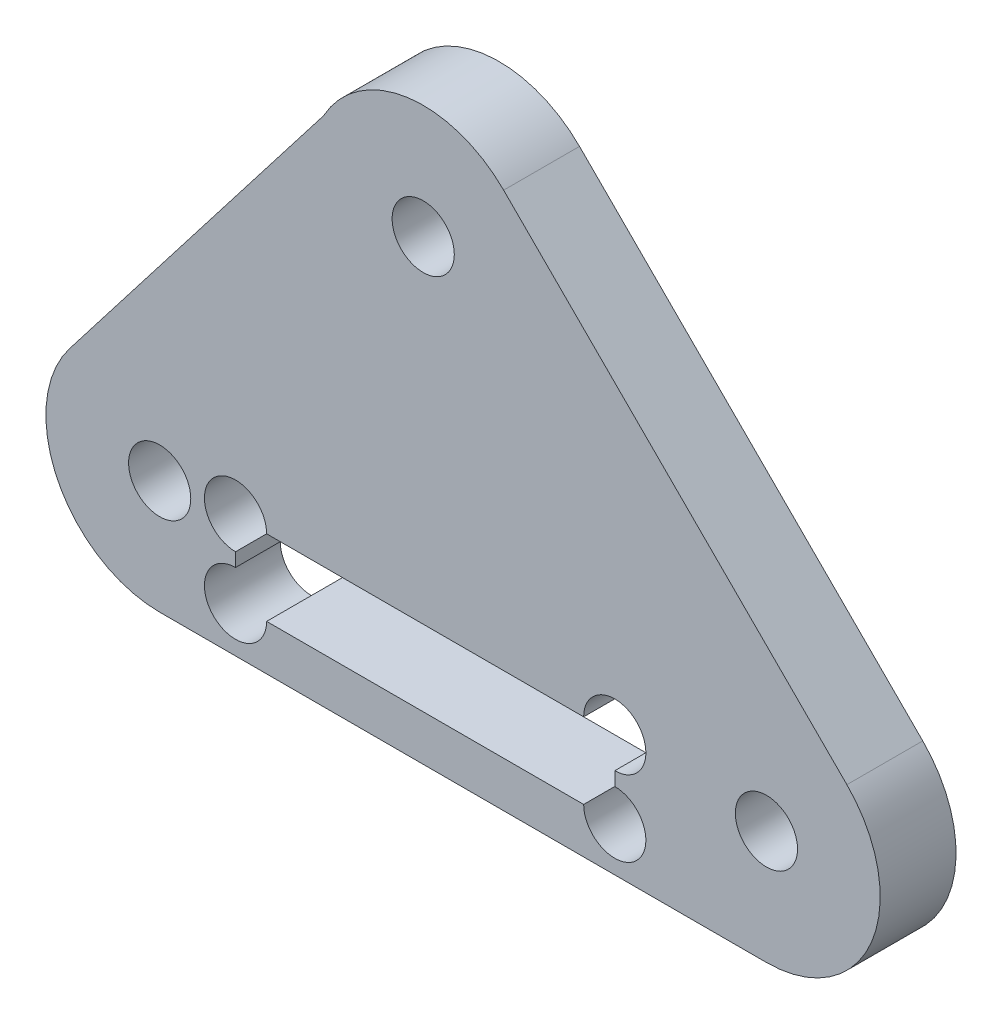
from build123d import *

# Parameters (mm, degrees)
SCHIZZO1_R                   = 2.05
SCHIZZO1_W                   = 25
SCHIZZO1_H                   = 5
ESTRUSIONE_ESTRUSIONE2_DEPTH = 5
CUT_EXTRUDE1_REACH           = 7
SKETCH1_R                    = 2.05


with BuildPart() as part:
    # Schizzo1 → Estrusione-Estrusione2 (new body)
    with BuildSketch(Plane.XY):
        with BuildLine():
            Line((-22.627416998, -7.5), (0, -7.5))
            ThreePointArc((0, -7.5), (6.929096494, -2.870125743), (5.303300859, 5.303300859))
            Line((5.303300859, 5.303300859), (-17.324116139, 27.930717857))
            ThreePointArc((-17.324116139, 27.930717857), (-23.686333927, 30.052287026), (-29.20181593, 26.236749163))
            Line((-29.20181593, 26.236749163), (-45.934294533, 4.586300077))
            ThreePointArc((-45.934294533, 4.586300077), (-46.732282324, -3.305506726), (-40, -7.5))
            Line((-40, -7.5), (-22.627416998, -7.5))
        make_face()
        Circle(SCHIZZO1_R, mode=Mode.SUBTRACT)
        with Locations((-22.627416998, 22.627416998)):
            Circle(SCHIZZO1_R, mode=Mode.SUBTRACT)
        with Locations((-40, 0)):
            Circle(SCHIZZO1_R, mode=Mode.SUBTRACT)
        with Locations((-22.5, -2)):
            Rectangle(SCHIZZO1_W, SCHIZZO1_H, mode=Mode.SUBTRACT)
    extrude(amount=ESTRUSIONE_ESTRUSIONE2_DEPTH)

    # Sketch1 → Cut-Extrude1 (cut, up to next)
    with BuildSketch(Plane.XY.offset(5), mode=Mode.PRIVATE) as cut_extrude1_sk1:
        with Locations((-35, 0.5)):
            Circle(SKETCH1_R)
    cut_extrude1_tool1 = extrude(cut_extrude1_sk1.sketch, amount=-CUT_EXTRUDE1_REACH, mode=Mode.PRIVATE) & part.part
    add(cut_extrude1_tool1.solids().sort_by_distance((-35, 0.5, 5))[0], mode=Mode.SUBTRACT)
    # Sketch1 → Cut-Extrude1 (cut, up to next)
    with BuildSketch(Plane.XY.offset(5), mode=Mode.PRIVATE) as cut_extrude1_sk2:
        with Locations((-35, -4.5)):
            Circle(SKETCH1_R)
    cut_extrude1_tool2 = extrude(cut_extrude1_sk2.sketch, amount=-CUT_EXTRUDE1_REACH, mode=Mode.PRIVATE) & part.part
    add(cut_extrude1_tool2.solids().sort_by_distance((-35, -4.5, 5))[0], mode=Mode.SUBTRACT)
    # Sketch1 → Cut-Extrude1 (cut, up to next)
    with BuildSketch(Plane.XY.offset(5), mode=Mode.PRIVATE) as cut_extrude1_sk3:
        with Locations((-10, -4.5)):
            Circle(SKETCH1_R)
    cut_extrude1_tool3 = extrude(cut_extrude1_sk3.sketch, amount=-CUT_EXTRUDE1_REACH, mode=Mode.PRIVATE) & part.part
    add(cut_extrude1_tool3.solids().sort_by_distance((-10, -4.5, 5))[0], mode=Mode.SUBTRACT)
    # Sketch1 → Cut-Extrude1 (cut, up to next)
    with BuildSketch(Plane.XY.offset(5), mode=Mode.PRIVATE) as cut_extrude1_sk4:
        with Locations((-10, 0.5)):
            Circle(SKETCH1_R)
    cut_extrude1_tool4 = extrude(cut_extrude1_sk4.sketch, amount=-CUT_EXTRUDE1_REACH, mode=Mode.PRIVATE) & part.part
    add(cut_extrude1_tool4.solids().sort_by_distance((-10, 0.5, 5))[0], mode=Mode.SUBTRACT)


solid = part.part
